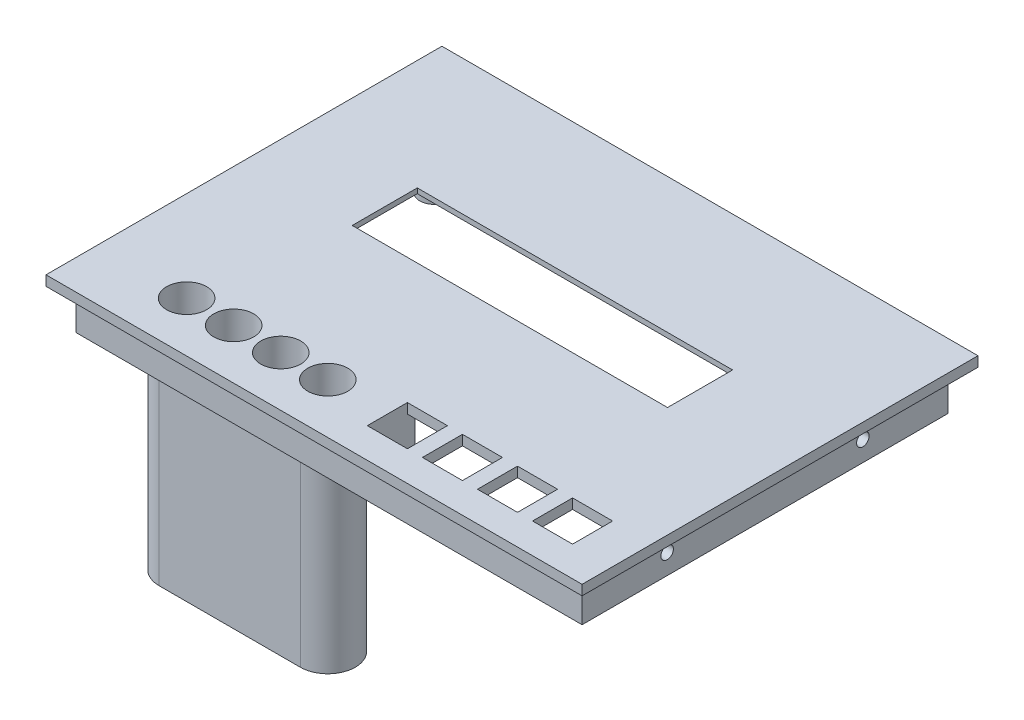
from build123d import *
from build123d.topology import SkipClean

# Parameters (mm, degrees)
SKETCH1_W                 = 78.1
SKETCH1_H                 = 55.9
BOSS_EXTRUDE1_DEPTH       = 3
SKETCH2_R                 = 1.25
CUT_EXTRUDE1_DEPTH        = 68
SKETCH4_W                 = 82.1
SKETCH4_H                 = 59.9
SKETCH4_W_2               = 78.1
SKETCH4_H_2               = 55.9
BOSS_EXTRUDE3_DEPTH       = 3
SKETCH6_R                 = 3
SKETCH6_R_2               = 1.25
BOSS_EXTRUDE4_DEPTH       = 3.5
SKETCH7_W                 = 82.1
SKETCH7_H                 = 16.2
BOSS_EXTRUDE5_DEPTH       = 3
SKETCH8_W                 = 82.1
SKETCH8_H                 = 50.5
BOSS_EXTRUDE6_DEPTH       = 3
SKETCH10_W                = 76.1
SKETCH10_H                = 3
BOSS_EXTRUDE7_DEPTH       = 20
SKETCH12_W                = 79.1
SKETCH12_H                = 50.5
BOSS_EXTRUDE8_DEPTH       = 3
SKETCH17_W                = 105.1
SKETCH17_H                = 50.5
BOSS_EXTRUDE13_DEPTH      = 1
BOSS_EXTRUDE13_DEPTH_BACK = 2
SKETCH18_W                = 11.5
SKETCH18_H                = 7.7
SKETCH18_W_2              = 39.6
SKETCH18_H_2              = 9
CUT_EXTRUDE4_DEPTH        = 9
SKETCH19_W                = 80.1
SKETCH19_H                = 50.5
BOSS_EXTRUDE14_DEPTH      = 3
SKETCH20_R                = 19
SKETCH20_R_2              = 1.5
CUT_EXTRUDE5_DEPTH        = 3
SKETCH22_R                = 2.5
CUT_EXTRUDE6_DEPTH        = 3
SKETCH23_R                = 1.5
BOSS_EXTRUDE16_DEPTH      = 3
SKETCH25_W                = 108.1
SKETCH25_H                = 50.5
CUT_EXTRUDE8_DEPTH        = 0.5
SKETCH26_W                = 79.6
SKETCH26_H                = 50.5
CUT_EXTRUDE9_DEPTH        = 0.5
SKETCH27_W                = 107.6
SKETCH27_H                = 50.5
CUT_EXTRUDE10_DEPTH       = 0.5
SKETCH28_W                = 79.1
SKETCH28_H                = 50.5
CUT_EXTRUDE11_DEPTH       = 0.5
SKETCH30_W                = 101.1
SKETCH30_H                = 73.1
BOSS_EXTRUDE17_DEPTH      = 2
BOSS_EXTRUDE17_DEPTH_BACK = 6
SKETCH31_W                = 39.6
SKETCH31_H                = 15.2
CUT_EXTRUDE12_DEPTH       = 18
SKETCH32_R                = 4
CUT_EXTRUDE13_DEPTH       = 788
SKETCH35_W                = 128.237297138
SKETCH35_H                = 101.417338931
CUT_EXTRUDE16_DEPTH       = 109
SKETCH36_W                = 107.1
SKETCH36_H                = 79.1
SKETCH36_W_2              = 102.1
SKETCH36_H_2              = 74.1
BOSS_EXTRUDE18_DEPTH      = 2
SKETCH37_W                = 107.1
SKETCH37_H                = 79.1
SKETCH37_W_2              = 102.1
SKETCH37_H_2              = 74.1
CUT_EXTRUDE17_DEPTH       = 6
SKETCH38_W                = 102.1
SKETCH38_H                = 74.1
SKETCH38_W_2              = 42.302719986
SKETCH38_H_2              = 18.764227688
BOSS_EXTRUDE19_DEPTH      = 2
SKETCH39_W                = 98.1
SKETCH39_H                = 70.1
CUT_EXTRUDE18_DEPTH       = 6
SKETCH40_R                = 4
BOSS_EXTRUDE21_DEPTH      = 20
SKETCH43_W                = 43.5
SKETCH43_H                = 1.5
CUT_EXTRUDE19_DEPTH       = 20
SKETCH44_W                = 22
SKETCH44_H                = 1.5
CUT_EXTRUDE20_DEPTH       = 20
FILLET1_R                 = 3
SKETCH45_W                = 73.258832398
SKETCH45_H                = 44.668177242
CUT_EXTRUDE21_DEPTH       = 63
CUT_EXTRUDE22_DEPTH       = 380
CUT_EXTRUDE22_DEPTH_BACK  = 374
BOSS_EXTRUDE23_DEPTH      = 2
SKETCH50_R                = 4
BOSS_EXTRUDE24_DEPTH      = 23
FILLET2_R                 = 3
SKETCH51_W                = 22
SKETCH51_H                = 0.5
CUT_EXTRUDE23_DEPTH       = 23
SKETCH52_W                = 22
SKETCH52_H                = 0.5
CUT_EXTRUDE24_DEPTH       = 23
SKETCH53_W                = 8
SKETCH53_H                = 8
CUT_EXTRUDE25_DEPTH       = 23
CUT_EXTRUDE26_DEPTH       = 23
SKETCH56_W                = 3.4
SKETCH56_H                = 1.5
SKETCH56_H_2              = 8
BOSS_EXTRUDE25_DEPTH      = 6
SKETCH58_W                = 4.9
SKETCH58_H                = 11
BOSS_EXTRUDE26_DEPTH      = 6
SKETCH61_R                = 1
CUT_EXTRUDE27_DEPTH       = 6
SKETCH62_W                = 3.4
SKETCH62_H                = 15.6
BOSS_EXTRUDE27_DEPTH      = 6
SKETCH64_W                = 4.9
SKETCH64_H                = 11
SKETCH64_R                = 1
SKETCH64_W_2              = 1.5
SKETCH64_H_2              = 70.1
BOSS_EXTRUDE28_DEPTH      = 2
BOSS_EXTRUDE29_DEPTH      = 8
SKETCH67_W                = 107.1
SKETCH67_H                = 79.1
SKETCH67_R                = 4
SKETCH67_W_2              = 8
SKETCH67_H_2              = 8
BOSS_EXTRUDE30_DEPTH      = 22
SKETCH68_W                = 8.1
SKETCH68_H                = 59.1
CUT_EXTRUDE28_DEPTH       = 22
SKETCH70_R                = 1.25
CUT_EXTRUDE29_DEPTH       = 22
SKETCH71_W                = 63
SKETCH71_H                = 13
CUT_EXTRUDE30_DEPTH       = 22
SKETCH72_W                = 72.2
SKETCH72_H                = 25
CUT_EXTRUDE31_DEPTH       = 1
SKETCH73_R                = 2.930769111
SKETCH73_R_2              = 1.25
SKETCH73_R_3              = 2.93
SKETCH73_W                = 75
SKETCH73_H                = 27.649527195
SKETCH73_W_2              = 72.2
SKETCH73_H_2              = 25
BOSS_EXTRUDE31_DEPTH      = 3
SKETCH74_R                = 2.93
SKETCH74_R_2              = 1.25
SKETCH74_R_3              = 2.930769111
BOSS_EXTRUDE32_DEPTH      = 3.5
SKETCH75_W                = 41
SKETCH75_H                = 1.5
BOSS_EXTRUDE33_DEPTH      = 22
SKETCH76_R                = 1.25
BOSS_EXTRUDE34_DEPTH      = 2
SKETCH78_W                = 107.1
SKETCH78_H                = 79.1
SKETCH78_W_2              = 101.1
SKETCH78_H_2              = 73.1
CUT_EXTRUDE32_DEPTH       = 22
SKETCH79_W                = 20.5
SKETCH79_H                = 1.5
CUT_EXTRUDE33_DEPTH       = 22
SKETCH80_W                = 77.6
SKETCH80_H                = 1.5
SKETCH80_R                = 1
SKETCH80_W_2              = 4.9
SKETCH80_H_2              = 26.6
CUT_EXTRUDE34_DEPTH       = 22
SKETCH81_R                = 1
CUT_EXTRUDE35_DEPTH       = 22
SKETCH82_W                = 41
SKETCH82_H                = 11
CUT_EXTRUDE36_DEPTH       = 22
SKETCH85_R                = 1.25
CUT_EXTRUDE38_DEPTH       = 9
SKETCH86_R                = 1.25
CUT_EXTRUDE39_DEPTH       = 9
SKETCH88_W                = 20.5
SKETCH88_H                = 1.5
BOSS_EXTRUDE35_DEPTH      = 4
SKETCH89_W                = 4.9
SKETCH89_H                = 45
BOSS_EXTRUDE36_DEPTH      = 9
SKETCH90_W                = 4.9
SKETCH90_H                = 73.1
BOSS_EXTRUDE37_DEPTH      = 9
SKETCH91_R                = 1.25
CUT_EXTRUDE41_DEPTH       = 9
SKETCH92_W                = 61.396361311
SKETCH92_H                = 8
BOSS_EXTRUDE38_DEPTH      = 4.9
SKETCH94_R                = 1.25
CUT_EXTRUDE42_DEPTH       = 4.9
SKETCH96_R                = 1.25
CUT_EXTRUDE43_DEPTH       = 9.9
SKETCH97_R                = 1.25
CUT_EXTRUDE44_DEPTH       = 9.9


with BuildPart() as part:
    # Sketch1 → Boss-Extrude1 (new body)
    with BuildSketch(Plane(origin=(0, 0, 0), x_dir=(1, 0, 0), z_dir=(0, 1, 0))):
        Rectangle(SKETCH1_W, SKETCH1_H)
    extrude(amount=BOSS_EXTRUDE1_DEPTH)

    # Sketch2 → Cut-Extrude1 (cut)
    with BuildSketch(Plane(origin=(0, 3, 0), x_dir=(1, 0, 0), z_dir=(0, 1, 0))):
        with Locations(Location((-35.9, 20.9, 0), (0, 0, 270))):
            Circle(SKETCH2_R)
        with Locations(Location((-35.9, -24.8, 0), (0, 0, 270))):
            Circle(SKETCH2_R)
        with Locations(Location((35.9, -24.8, 0), (0, 0, 270))):
            Circle(SKETCH2_R)
        with Locations(Location((35.9, 24.8, 0), (0, 0, 270))):
            Circle(SKETCH2_R)
    extrude(amount=-CUT_EXTRUDE1_DEPTH, mode=Mode.SUBTRACT)

    # Sketch4 → Boss-Extrude3 (add)
    with BuildSketch(Plane(origin=(0, 0, 0), x_dir=(-1, 0, 0), z_dir=(0, -1, 0))):
        Rectangle(SKETCH4_W, SKETCH4_H)
        Rectangle(SKETCH4_W_2, SKETCH4_H_2, mode=Mode.SUBTRACT)
    extrude(amount=-BOSS_EXTRUDE3_DEPTH)

    # Sketch6 → Boss-Extrude4 (add)
    with BuildSketch(Plane(origin=(0, 3, 0), x_dir=(1, 0, 0), z_dir=(0, 1, 0))):
        with Locations(Location((-35.9, 20.9, 0), (0, 0, 90))):
            Circle(SKETCH6_R)
        with Locations(Location((-35.9, 20.9, 0), (0, 0, 270))):
            Circle(SKETCH6_R_2, mode=Mode.SUBTRACT)
        with Locations(Location((35.9, 24.8, 0), (0, 0, 90))):
            Circle(SKETCH6_R)
        with Locations(Location((35.9, 24.8, 0), (0, 0, 270))):
            Circle(SKETCH6_R_2, mode=Mode.SUBTRACT)
        with Locations(Location((35.9, -24.8, 0), (0, 0, 90))):
            Circle(SKETCH6_R)
        with Locations(Location((35.9, -24.8, 0), (0, 0, 270))):
            Circle(SKETCH6_R_2, mode=Mode.SUBTRACT)
        with Locations(Location((-35.9, -24.8, 0), (0, 0, 90))):
            Circle(SKETCH6_R)
        with Locations(Location((-35.9, -24.8, 0), (0, 0, 270))):
            Circle(SKETCH6_R_2, mode=Mode.SUBTRACT)
    extrude(amount=BOSS_EXTRUDE4_DEPTH)

    # Sketch7 → Boss-Extrude5 (add)
    with BuildSketch(Plane(origin=(0, 0, 0), x_dir=(-1, 0, 0), z_dir=(0, -1, 0))):
        with Locations((0, 38.05)):
            Rectangle(SKETCH7_W, SKETCH7_H)
    extrude(amount=-BOSS_EXTRUDE5_DEPTH)

    # Sketch8 → Boss-Extrude6 (add)
    with BuildSketch(Plane(origin=(0, 0, -46.15), x_dir=(-1, 0, 0), z_dir=(0, 0, -1))):
        with Locations((0, 25.25)):
            Rectangle(SKETCH8_W, SKETCH8_H)
    extrude(amount=BOSS_EXTRUDE6_DEPTH)

    # Sketch10 → Boss-Extrude7 (add)
    with BuildSketch(Plane(origin=(41.05, 0, 0), x_dir=(0, 0, -1), z_dir=(1, 0, 0))):
        Polygon((49.15, 50.5), (46.15, 50.5), (46.15, 3), (46.15, 0), (49.15, 0), align=None)
        with Locations((8.1, 1.5)):
            Rectangle(SKETCH10_W, SKETCH10_H)
    extrude(amount=BOSS_EXTRUDE7_DEPTH)

    # Sketch12 → Boss-Extrude8 (add)
    with BuildSketch(Plane.ZY.offset(41.05)):
        with Locations((-9.6, 25.25)):
            Rectangle(SKETCH12_W, SKETCH12_H)
    extrude(amount=BOSS_EXTRUDE8_DEPTH)

    # Sketch17 → Boss-Extrude13 (add, two sides)
    with BuildSketch(Plane.XY.offset(29.95)) as boss_extrude13_sk:
        with Locations((8.5, 25.25)):
            Rectangle(SKETCH17_W, SKETCH17_H)
    extrude(amount=BOSS_EXTRUDE13_DEPTH)
    extrude(boss_extrude13_sk.sketch, amount=-BOSS_EXTRUDE13_DEPTH_BACK)

    # Sketch18 → Cut-Extrude4 (cut)
    with BuildSketch(Plane(origin=(0, 0, 27.95), x_dir=(-1, 0, 0), z_dir=(0, 0, -1))):
        with Locations((-21.6, 9.95)):
            Rectangle(SKETCH18_W, SKETCH18_H)
        with Locations((11.35, 17.6)):
            Rectangle(SKETCH18_W_2, SKETCH18_H_2)
    extrude(amount=-CUT_EXTRUDE4_DEPTH, mode=Mode.SUBTRACT)

    # Sketch19 → Boss-Extrude14 (add)
    with BuildSketch(Plane(origin=(61.05, 0, 0), x_dir=(0, 0, -1), z_dir=(1, 0, 0))):
        with Locations((9.1, 25.25)):
            Rectangle(SKETCH19_W, SKETCH19_H)
    extrude(amount=BOSS_EXTRUDE14_DEPTH)

    # Sketch20 → Cut-Extrude5 (cut)
    with BuildSketch(Plane.ZY.offset(-61.05)):
        with Locations((-24.15, 25)):
            Circle(SKETCH20_R)
        with Locations((-8.4, 40.75)):
            Circle(SKETCH20_R_2)
        with Locations((-39.9, 40.75)):
            Circle(SKETCH20_R_2)
        with Locations((-8.4, 9.25)):
            Circle(SKETCH20_R_2)
        with Locations((-39.9, 9.25)):
            Circle(SKETCH20_R_2)
    extrude(amount=-CUT_EXTRUDE5_DEPTH, mode=Mode.SUBTRACT)

    # Sketch22 → Cut-Extrude6 (cut)
    with BuildSketch(Plane(origin=(-41.05, 0, 0), x_dir=(0, 0, -1), z_dir=(1, 0, 0))):
        with Locations((14.225, 12.6875)):
            Circle(SKETCH22_R)
        with Locations((14.225, 22.0625)):
            Circle(SKETCH22_R)
        with Locations((18.5, 17.375)):
            Circle(SKETCH22_R)
        with Locations((22.775, 22.0625)):
            Circle(SKETCH22_R)
        with Locations((22.775, 12.6875)):
            Circle(SKETCH22_R)
        with Locations((14.225, 31.4375)):
            Circle(SKETCH22_R)
        with Locations((18.5, 26.75)):
            Circle(SKETCH22_R)
        with Locations((22.775, 31.4375)):
            Circle(SKETCH22_R)
        with Locations((18.5, 36.125)):
            Circle(SKETCH22_R)
        with Locations((14.225, 40.8125)):
            Circle(SKETCH22_R)
        with Locations((22.775, 40.8125)):
            Circle(SKETCH22_R)
        with Locations((27.05, 36.125)):
            Circle(SKETCH22_R)
        with Locations((31.325, 40.8125)):
            Circle(SKETCH22_R)
        with Locations((39.875, 40.8125)):
            Circle(SKETCH22_R)
        with Locations((35.6, 36.125)):
            Circle(SKETCH22_R)
        with Locations((39.875, 31.4375)):
            Circle(SKETCH22_R)
        with Locations((31.325, 31.4375)):
            Circle(SKETCH22_R)
        with Locations((27.05, 26.75)):
            Circle(SKETCH22_R)
        with Locations((31.325, 22.0625)):
            Circle(SKETCH22_R)
        with Locations((39.875, 22.0625)):
            Circle(SKETCH22_R)
        with Locations((35.6, 26.75)):
            Circle(SKETCH22_R)
        with Locations((27.05, 17.375)):
            Circle(SKETCH22_R)
        with Locations((31.325, 12.6875)):
            Circle(SKETCH22_R)
        with Locations((39.875, 12.6875)):
            Circle(SKETCH22_R)
        with Locations((35.6, 17.375)):
            Circle(SKETCH22_R)
        with Locations((18.5, 8)):
            Circle(SKETCH22_R)
        with Locations((27.05, 8)):
            Circle(SKETCH22_R)
        with Locations((35.6, 8)):
            Circle(SKETCH22_R)
    extrude(amount=-CUT_EXTRUDE6_DEPTH, mode=Mode.SUBTRACT)

    # Sketch23 → Boss-Extrude16 (add)
    with BuildSketch(Plane(origin=(64.05, 0, 0), x_dir=(0, 0, -1), z_dir=(1, 0, 0))):
        with Locations((8.4, 9.25)):
            Circle(SKETCH23_R)
        with Locations((39.9, 40.75)):
            Circle(SKETCH23_R)
    extrude(amount=-BOSS_EXTRUDE16_DEPTH)

    # Sketch25 → Cut-Extrude8 (cut)
    with BuildSketch(Plane.XY.offset(30.95)):
        with Locations((10, 25.25)):
            Rectangle(SKETCH25_W, SKETCH25_H)
    extrude(amount=-CUT_EXTRUDE8_DEPTH, mode=Mode.SUBTRACT)

    # Sketch26 → Cut-Extrude9 (cut)
    with BuildSketch(Plane(origin=(64.05, 0, 0), x_dir=(0, 0, -1), z_dir=(1, 0, 0))):
        with Locations((9.35, 25.25)):
            Rectangle(SKETCH26_W, SKETCH26_H)
    extrude(amount=-CUT_EXTRUDE9_DEPTH, mode=Mode.SUBTRACT)

    # Sketch27 → Cut-Extrude10 (cut)
    with BuildSketch(Plane(origin=(0, 0, -49.15), x_dir=(-1, 0, 0), z_dir=(0, 0, -1))):
        with Locations((-9.75, 25.25)):
            Rectangle(SKETCH27_W, SKETCH27_H)
    extrude(amount=-CUT_EXTRUDE10_DEPTH, mode=Mode.SUBTRACT)

    # Sketch28 → Cut-Extrude11 (cut)
    with BuildSketch(Plane.ZY.offset(44.05)):
        with Locations((-9.1, 25.25)):
            Rectangle(SKETCH28_W, SKETCH28_H)
    extrude(amount=-CUT_EXTRUDE11_DEPTH, mode=Mode.SUBTRACT)

    # Sketch31 → Cut-Extrude12 (cut)
    with BuildSketch(Plane(origin=(0, 3, 0), x_dir=(1, 0, 0), z_dir=(0, 1, 0))):
        with Locations((-11.35, -20.35)):
            Rectangle(SKETCH31_W, SKETCH31_H)
    extrude(amount=-CUT_EXTRUDE12_DEPTH, mode=Mode.SUBTRACT)


with BuildPart() as body_2:
    # Sketch30 → Boss-Extrude17 (new, two sides)
    with BuildSketch(Plane(origin=(0, 50.5, 0), x_dir=(1, 0, 0), z_dir=(0, 1, 0))) as boss_extrude17_sk:
        with Locations((10, 9.1)):
            Rectangle(SKETCH30_W, SKETCH30_H)
    extrude(amount=BOSS_EXTRUDE17_DEPTH)
    extrude(boss_extrude17_sk.sketch, amount=-BOSS_EXTRUDE17_DEPTH_BACK)


with BuildPart() as cut_extrude13_tool:
    # Sketch32 → Cut-Extrude13 (new body)
    with BuildSketch(Plane.XZ):
        with Locations(Location((2.73, 16.581093047, 0), (0, 0, 270))):
            Circle(SKETCH32_R)
        with Locations(Location((-6.607184449, 16.581093047, 0), (0, 0, 270))):
            Circle(SKETCH32_R)
        with Locations(Location((-16.03, 16.55, 0), (0, 0, 270))):
            Circle(SKETCH32_R)
        with Locations(Location((-25.43, 16.55, 0), (0, 0, 270))):
            Circle(SKETCH32_R)
    extrude(amount=-CUT_EXTRUDE13_DEPTH)


with BuildPart() as part_1:
    add(part.part)

    # Cut-Extrude13: cut by cut_extrude13_tool
    add(cut_extrude13_tool.part, mode=Mode.SUBTRACT)

    # Sketch35 → Cut-Extrude16 (cut)
    with BuildSketch(Plane.XY.offset(30.45)):
        with Locations((20.568648569, -6.208669466)):
            Rectangle(SKETCH35_W, SKETCH35_H)
    extrude(amount=-CUT_EXTRUDE16_DEPTH, mode=Mode.SUBTRACT)

    # Sketch36 → Boss-Extrude18 (add)
    with BuildSketch(Plane(origin=(0, 50.5, 0), x_dir=(1, 0, 0), z_dir=(0, 1, 0))):
        with Locations((10, 9.1)):
            Rectangle(SKETCH36_W, SKETCH36_H)
        with Locations((10, 9.1)):
            Rectangle(SKETCH36_W_2, SKETCH36_H_2, mode=Mode.SUBTRACT)
    extrude(amount=BOSS_EXTRUDE18_DEPTH)

    # Sketch37 → Cut-Extrude17 (cut)
    with BuildSketch(Plane(origin=(0, 44.5, 0), x_dir=(-1, 0, 0), z_dir=(0, -1, 0))):
        with Locations((-10, 9.1)):
            Rectangle(SKETCH37_W, SKETCH37_H)
        with Locations((-10, 9.1)):
            Rectangle(SKETCH37_W_2, SKETCH37_H_2, mode=Mode.SUBTRACT)
    extrude(amount=-CUT_EXTRUDE17_DEPTH, mode=Mode.SUBTRACT)



with BuildPart() as body_2_1:
    add(body_2.part)

    # Cut-Extrude13: cut by cut_extrude13_tool
    add(cut_extrude13_tool.part, mode=Mode.SUBTRACT)


with BuildPart() as part_2:
    add(part_1.part)

    add(body_2_1.part)  # Boss-Extrude19 merges body 2
    # Sketch38 → Boss-Extrude19 (add)
    with BuildSketch(Plane(origin=(0, 52.5, 0), x_dir=(1, 0, 0), z_dir=(0, 1, 0))):
        with Locations((10, 9.1)):
            Rectangle(SKETCH38_W, SKETCH38_H)
        with Locations((-11.151359993, -15.547609528)):
            Rectangle(SKETCH38_W_2, SKETCH38_H_2, mode=Mode.SUBTRACT)
    extrude(amount=-BOSS_EXTRUDE19_DEPTH)

    # Sketch39 → Cut-Extrude18 (cut)
    with BuildSketch(Plane(origin=(0, 44.5, 0), x_dir=(-1, 0, 0), z_dir=(0, -1, 0))):
        with Locations((-10, 9.1)):
            Rectangle(SKETCH39_W, SKETCH39_H)
    extrude(amount=-CUT_EXTRUDE18_DEPTH, mode=Mode.SUBTRACT)

    # Sketch40 → Boss-Extrude21 (add)
    with BuildSketch(Plane(origin=(0, 50.5, 0), x_dir=(-1, 0, 0), z_dir=(0, -1, 0))):
        with BuildLine():
            Line((25.43, -11.181722504), (-2.73, -11.243908599))
            ThreePointArc((-2.73, -11.243908599), (-8.067184449, -16.581093047), (-2.73, -21.918277496))
            Line((-2.73, -21.918277496), (25.43, -21.918277496))
            ThreePointArc((25.43, -21.918277496), (30.798277496, -16.55), (25.43, -11.181722504))
        make_face()
        with Locations(Location((6.607184449, -16.581093047, 0), (0, 0, 90))):
            Circle(SKETCH40_R, mode=Mode.SUBTRACT)
        with Locations(Location((16.03, -16.55, 0), (0, 0, 90))):
            Circle(SKETCH40_R, mode=Mode.SUBTRACT)
        with Locations(Location((25.43, -16.55, 0), (0, 0, 90))):
            Circle(SKETCH40_R, mode=Mode.SUBTRACT)
        with Locations(Location((-2.73, -16.581093047, 0), (0, 0, 90))):
            Circle(SKETCH40_R, mode=Mode.SUBTRACT)
    extrude(amount=BOSS_EXTRUDE21_DEPTH)

    # Sketch43 → Cut-Extrude19 (cut)
    with BuildSketch(Plane.ZY.offset(-59.05)):
        with Locations((-22.4, 45.25)):
            Rectangle(SKETCH43_W, SKETCH43_H)
    extrude(amount=-CUT_EXTRUDE19_DEPTH, mode=Mode.SUBTRACT)

    # Sketch44 → Cut-Extrude20 (cut)
    with BuildSketch(Plane.XY.offset(-44.15)):
        with Locations((49.55, 45.25)):
            Rectangle(SKETCH44_W, SKETCH44_H)
    extrude(amount=-CUT_EXTRUDE20_DEPTH, mode=Mode.SUBTRACT)

    # Fillet1
    fillet1_edges = [part_2.edges().sort_by_distance(p)[0] for p in [
        (-11.35, 50.5, 21.918277496),
        (-30.798277496, 50.5, 16.55),
        (-11.35, 50.5, 11.212815551),
        (8.067184449, 50.5, 16.581093047),
    ]]
    fillet(fillet1_edges, radius=FILLET1_R)

    # Sketch45 → Cut-Extrude21 (cut)
    with BuildSketch(Plane(origin=(0, 50.5, 0), x_dir=(-1, 0, 0), z_dir=(0, -1, 0))):
        with Locations((2.420583801, -3.615911379)):
            Rectangle(SKETCH45_W, SKETCH45_H)
    extrude(amount=CUT_EXTRUDE21_DEPTH, mode=Mode.SUBTRACT)

    # Sketch3 → Cut-Extrude22 (cut, two sides)
    with BuildSketch(Plane(origin=(0, 3, 0), x_dir=(1, 0, 0), z_dir=(0, 1, 0))) as cut_extrude22_sk:
        with BuildLine():
            ThreePointArc((-21.45, -20.45), (-25.45, -16.45), (-29.45, -20.45))
            Line((-29.45, -20.45), (-25.45, -20.45))
            Line((-25.45, -20.45), (-21.45, -20.45))
        make_face()
        with BuildLine():
            ThreePointArc((-29.45, -20.45), (-28.278427125, -23.278427125), (-25.45, -24.45))
            Line((-25.45, -24.45), (-25.45, -20.45))
            Line((-25.45, -20.45), (-29.45, -20.45))
        make_face()
        with BuildLine():
            Line((-25.45, -20.45), (-25.45, -24.45))
            ThreePointArc((-25.45, -24.45), (-22.621572875, -23.278427125), (-21.45, -20.45))
            Line((-21.45, -20.45), (-25.45, -20.45))
        make_face()
        with BuildLine():
            ThreePointArc((-20.05, -20.45), (-18.878427125, -23.278427125), (-16.05, -24.45))
            Line((-16.05, -24.45), (-16.05, -20.45))
            Line((-16.05, -20.45), (-20.05, -20.45))
        make_face()
        with BuildLine():
            Line((-16.05, -20.45), (-16.05, -24.45))
            ThreePointArc((-16.05, -24.45), (-13.221572875, -23.278427125), (-12.05, -20.45))
            ThreePointArc((-12.05, -20.45), (-16.05, -16.45), (-20.05, -20.45))
            Line((-20.05, -20.45), (-16.05, -20.45))
        make_face()
        with BuildLine():
            ThreePointArc((-2.65, -20.45), (-9.478427125, -17.621572875), (-6.65, -24.45))
            Line((-6.65, -24.45), (-6.65, -20.45))
            Line((-6.65, -20.45), (-2.65, -20.45))
        make_face()
        with BuildLine():
            Line((-6.65, -20.45), (-6.65, -24.45))
            ThreePointArc((-6.65, -24.45), (-3.821572875, -23.278427125), (-2.65, -20.45))
            Line((-2.65, -20.45), (-6.65, -20.45))
        make_face()
        with BuildLine():
            ThreePointArc((-1.25, -20.45), (-0.078427125, -23.278427125), (2.75, -24.45))
            Line((2.75, -24.45), (2.75, -20.45))
            Line((2.75, -20.45), (-1.25, -20.45))
        make_face()
        with BuildLine():
            Line((2.75, -20.45), (2.75, -24.45))
            ThreePointArc((2.75, -24.45), (5.578427125, -23.278427125), (6.75, -20.45))
            Line((6.75, -20.45), (2.75, -20.45))
        make_face()
        with BuildLine():
            Line((2.75, -20.45), (6.75, -20.45))
            ThreePointArc((6.75, -20.45), (2.75, -16.45), (-1.25, -20.45))
            Line((-1.25, -20.45), (2.75, -20.45))
        make_face()
    extrude(amount=CUT_EXTRUDE22_DEPTH, mode=Mode.SUBTRACT)
    extrude(cut_extrude22_sk.sketch, amount=-CUT_EXTRUDE22_DEPTH_BACK, mode=Mode.SUBTRACT)

    # Sketch49 → Boss-Extrude23 (add)
    with BuildSketch(Plane(origin=(0, 50.5, 0), x_dir=(-1, 0, 0), z_dir=(0, -1, 0))):
        with BuildLine():
            ThreePointArc((-6.241065865, -18.497448048), (-2.729322601, -16.450053445), (0.761065865, -18.533644999))
            ThreePointArc((0.761065865, -18.533644999), (1.140675875, -17.589987625), (1.27, -16.581093047))
            ThreePointArc((1.27, -16.581093047), (-3.718872221, -12.70525356), (-6.241065865, -18.497448048))
        make_face()
        with BuildLine():
            ThreePointArc((3.127745115, -18.554288913), (6.605736408, -16.450244916), (10.129439334, -18.476804135))
            ThreePointArc((10.129439334, -18.476804135), (10.485909725, -17.558584853), (10.607184449, -16.581093047))
            ThreePointArc((10.607184449, -16.581093047), (5.586830916, -12.713422086), (3.127745115, -18.554288913))
        make_face()
        with BuildLine():
            ThreePointArc((12.547568292, -18.517909906), (16.029487449, -16.450052596), (19.532431708, -18.482090094))
            ThreePointArc((19.532431708, -18.482090094), (19.90361116, -17.547565328), (20.03, -16.55))
            ThreePointArc((20.03, -16.55), (15.012583377, -12.681555427), (12.547568292, -18.517909906))
        make_face()
        with BuildLine():
            ThreePointArc((21.947568292, -18.517909906), (25.429487449, -16.450052596), (28.932431708, -18.482090094))
            ThreePointArc((28.932431708, -18.482090094), (29.30361116, -17.547565328), (29.43, -16.55))
            ThreePointArc((29.43, -16.55), (24.412583377, -12.681555427), (21.947568292, -18.517909906))
        make_face()
    extrude(amount=-BOSS_EXTRUDE23_DEPTH)

    # Sketch50 → Boss-Extrude24 (add)
    with SkipClean():  # the faces are left unmerged after this step: merging them gives an invalid solid
        with BuildSketch(Plane(origin=(0, 50.5, 0), x_dir=(-1, 0, 0), z_dir=(0, -1, 0))):
            with BuildLine():
                Line((-2.75, -25.95), (25.45, -25.95))
                ThreePointArc((25.45, -25.95), (30.95, -20.45), (25.45, -14.95))
                Line((25.45, -14.95), (-2.75, -14.95))
                ThreePointArc((-2.75, -14.95), (-8.25, -20.45), (-2.75, -25.95))
            make_face()
            with Locations(Location((16.05, -20.45, 0), (0, 0, 90))):
                Circle(SKETCH50_R, mode=Mode.SUBTRACT)
            with Locations(Location((6.65, -20.45, 0), (0, 0, 90))):
                Circle(SKETCH50_R, mode=Mode.SUBTRACT)
            with Locations(Location((25.45, -20.45, 0), (0, 0, 90))):
                Circle(SKETCH50_R, mode=Mode.SUBTRACT)
            with Locations(Location((-2.75, -20.45, 0), (0, 0, 90))):
                Circle(SKETCH50_R, mode=Mode.SUBTRACT)
        extrude(amount=BOSS_EXTRUDE24_DEPTH)

    # Fillet2
    fillet2_edges = [part_2.edges().sort_by_distance(p)[0] for p in [
        (-11.35, 50.5, 14.95),
        (8.25, 50.5, 20.45),
        (-30.95, 50.5, 20.45),
    ]]
    fillet(fillet2_edges, radius=FILLET2_R)

    # Sketch51 → Cut-Extrude23 (cut)
    with SkipClean():  # the faces are left unmerged after this step: merging them gives an invalid solid
        with BuildSketch(Plane(origin=(0, 0, -45.65), x_dir=(-1, 0, 0), z_dir=(0, 0, -1))):
            with Locations((-49.55, 46.25)):
                Rectangle(SKETCH51_W, SKETCH51_H)
        extrude(amount=-CUT_EXTRUDE23_DEPTH, mode=Mode.SUBTRACT)

    # Sketch52 → Cut-Extrude24 (cut)
    with SkipClean():  # the faces are left unmerged after this step: merging them gives an invalid solid
        with BuildSketch(Plane(origin=(60.55, 0, 0), x_dir=(0, 0, -1), z_dir=(1, 0, 0))):
            with Locations((11.65, 46.25)):
                Rectangle(SKETCH52_W, SKETCH52_H)
        extrude(amount=-CUT_EXTRUDE24_DEPTH, mode=Mode.SUBTRACT)

    # Sketch53 → Cut-Extrude25 (cut)
    with SkipClean():  # the faces are left unmerged after this step: merging them gives an invalid solid
        with BuildSketch(Plane(origin=(0, 52.5, 0), x_dir=(1, 0, 0), z_dir=(0, 1, 0))):
            with Locations((51.65, -20.45)):
                Rectangle(SKETCH53_W, SKETCH53_H)
            with Locations((40.65, -20.45)):
                Rectangle(SKETCH53_W, SKETCH53_H)
            with Locations((29.65, -20.45)):
                Rectangle(SKETCH53_W, SKETCH53_H)
            with Locations((18.65, -20.45)):
                Rectangle(SKETCH53_W, SKETCH53_H)
        extrude(amount=-CUT_EXTRUDE25_DEPTH, mode=Mode.SUBTRACT)

    # Sketch54 → Cut-Extrude26 (cut)
    with SkipClean():  # the faces are left unmerged after this step: merging them gives an invalid solid
        with BuildSketch(Plane(origin=(0, 27.5, 0), x_dir=(-1, 0, 0), z_dir=(0, -1, 0))):
            Polygon((-14.201290386, -14.95), (-2.75, -14.95), (25.45, -14.95), (35.501290386, -14.95), (35.501290386, -4.067232411), (-14.201290386, -4.067232411), align=None)
            with BuildLine():
                Line((35.501290386, -14.95), (25.45, -14.95))
                ThreePointArc((25.45, -14.95), (29.339087297, -16.560912703), (30.95, -20.45))
                ThreePointArc((30.95, -20.45), (29.339087297, -24.339087297), (25.45, -25.95))
                Line((25.45, -25.95), (35.501290386, -25.95))
                Line((35.501290386, -25.95), (35.501290386, -14.95))
            make_face()
            with BuildLine():
                ThreePointArc((-2.75, -25.95), (-8.25, -20.45), (-2.75, -14.95))
                Line((-2.75, -14.95), (-14.201290386, -14.95))
                Line((-14.201290386, -14.95), (-14.201290386, -25.95))
                Line((-14.201290386, -25.95), (-2.75, -25.95))
            make_face()
        extrude(amount=-CUT_EXTRUDE26_DEPTH, mode=Mode.SUBTRACT)

    # Sketch56 → Boss-Extrude25 (add)
    with SkipClean():  # the faces are left unmerged after this step: merging them gives an invalid solid
        with BuildSketch(Plane.XZ.offset(-50.5)):
            with Locations((57.35, 25.2)):
                Rectangle(SKETCH56_W, SKETCH56_H)
            with Locations((57.35, 20.45)):
                Rectangle(SKETCH56_W, SKETCH56_H_2)
            with Locations((57.35, 15.7)):
                Rectangle(SKETCH56_W, SKETCH56_H)
        extrude(amount=BOSS_EXTRUDE25_DEPTH)

    # Sketch58 → Boss-Extrude26 (add)
    with SkipClean():  # the faces are left unmerged after this step: merging them gives an invalid solid
        with BuildSketch(Plane.XZ.offset(-50.5)):
            with Locations((12.2, 20.45)):
                Rectangle(SKETCH58_W, SKETCH58_H)
        extrude(amount=BOSS_EXTRUDE26_DEPTH)

    # Sketch61 → Cut-Extrude27 (cut)
    with SkipClean():  # the faces are left unmerged after this step: merging them gives an invalid solid
        with BuildSketch(Plane(origin=(0, 44.5, 0), x_dir=(-1, 0, 0), z_dir=(0, -1, 0))):
            with Locations(Location((-58.15, -20.45, 0), (0, 0, 90))):
                Circle(SKETCH61_R)
            with Locations(Location((-12.15, -20.45, 0), (0, 0, 90))):
                Circle(SKETCH61_R)
        extrude(amount=-CUT_EXTRUDE27_DEPTH, mode=Mode.SUBTRACT)

    # Sketch62 → Boss-Extrude27 (add)
    with SkipClean():  # the faces are left unmerged after this step: merging them gives an invalid solid
        with BuildSketch(Plane(origin=(0, 44.5, 0), x_dir=(-1, 0, 0), z_dir=(0, -1, 0))):
            with Locations((-57.35, -7.15)):
                Rectangle(SKETCH62_W, SKETCH62_H)
        extrude(amount=-BOSS_EXTRUDE27_DEPTH)

    # Sketch64 → Boss-Extrude28 (add)
    with BuildSketch(Plane.XZ.offset(-44.5)):
        with Locations((12.2, 20.45)):
            Rectangle(SKETCH64_W, SKETCH64_H)
        with Locations(Location((12.15, 20.45, 0), (0, 0, 270))):
            Circle(SKETCH64_R, mode=Mode.SUBTRACT)
        Polygon((55.65, 27.45), (55.65, 25.95), (55.65, -0.65), (60.55, -0.65), (60.55, 27.45), align=None)
        with Locations(Location((58.15, 20.45, 0), (0, 0, 270))):
            Circle(SKETCH64_R, mode=Mode.SUBTRACT)
        Polygon((2.75, 25.95), (9.75, 25.95), (14.65, 25.95), (55.65, 25.95), (55.65, 27.45), (-40.55, 27.45), (-40.55, 25.95), (-39.05, 25.95), (-25.45, 25.95), align=None)
        with Locations((-39.8, -9.1)):
            Rectangle(SKETCH64_W_2, SKETCH64_H_2)
        Polygon((38.55, -44.15), (-39.05, -44.15), (-40.55, -44.15), (-40.55, -45.65), (38.55, -45.65), align=None)
    extrude(amount=BOSS_EXTRUDE28_DEPTH)

    # Sketch65 → Boss-Extrude29 (add)
    with BuildSketch(Plane(origin=(0, 50.5, 0), x_dir=(-1, 0, 0), z_dir=(0, -1, 0))):
        with BuildLine():
            Line((-2.75, -14.95), (-9.75, -14.95))
            Line((-9.75, -14.95), (-9.75, -25.95))
            Line((-9.75, -25.95), (-2.75, -25.95))
            ThreePointArc((-2.75, -25.95), (-8.25, -20.45), (-2.75, -14.95))
        make_face()
    extrude(amount=BOSS_EXTRUDE29_DEPTH)

    # Sketch67 → Boss-Extrude30 (add)
    with BuildSketch(Plane(origin=(0, 52.5, 0), x_dir=(1, 0, 0), z_dir=(0, 1, 0))):
        with Locations((10, 9.1)):
            Rectangle(SKETCH67_W, SKETCH67_H)
        with Locations(Location((2.75, -20.45, 0), (0, 0, 90))):
            Circle(SKETCH67_R, mode=Mode.SUBTRACT)
        with Locations(Location((-6.65, -20.45, 0), (0, 0, 90))):
            Circle(SKETCH67_R, mode=Mode.SUBTRACT)
        with Locations(Location((-16.05, -20.45, 0), (0, 0, 90))):
            Circle(SKETCH67_R, mode=Mode.SUBTRACT)
        with Locations(Location((-25.45, -20.45, 0), (0, 0, 90))):
            Circle(SKETCH67_R, mode=Mode.SUBTRACT)
        with Locations((51.65, -20.45)):
            Rectangle(SKETCH67_W_2, SKETCH67_H_2, mode=Mode.SUBTRACT)
        with Locations((40.65, -20.45)):
            Rectangle(SKETCH67_W_2, SKETCH67_H_2, mode=Mode.SUBTRACT)
        with Locations((29.65, -20.45)):
            Rectangle(SKETCH67_W_2, SKETCH67_H_2, mode=Mode.SUBTRACT)
        with Locations((18.65, -20.45)):
            Rectangle(SKETCH67_W_2, SKETCH67_H_2, mode=Mode.SUBTRACT)
    extrude(amount=BOSS_EXTRUDE30_DEPTH)

    # Sketch68 → Cut-Extrude28 (cut)
    with BuildSketch(Plane.XZ.offset(-50.5)):
        Polygon((14.65, -44.15), (59.05, -44.15), (59.05, -0.65), (55.65, -0.65), (55.65, 16.45), (47.65, 16.45), (44.65, 16.45), (36.65, 16.45), (33.65, 16.45), (25.65, 16.45), (22.65, 16.45), (14.65, 16.45), (14.65, 14.95), align=None)
        Polygon((-30.95, -44.15), (14.65, -44.15), (14.65, 14.95), (-25.45, 14.95), (-30.95, 14.95), align=None)
        with Locations((-35, -14.6)):
            Rectangle(SKETCH68_W, SKETCH68_H)
        Polygon((-39.05, 14.95), (-30.95, 14.95), (-30.95, 20.450000012), (-30.95, 25.95), (-39.05, 25.95), align=None)
        with BuildLine():
            Line((-30.95, 14.95), (-25.45, 14.95))
            ThreePointArc((-25.45, 14.95), (-29.339087301, 16.560912708), (-30.95, 20.450000012))
            Line((-30.95, 20.450000012), (-30.95, 14.95))
        make_face()
        with BuildLine():
            Line((-30.95, 25.95), (-30.95, 20.450000012))
            ThreePointArc((-30.95, 20.450000012), (-29.339087292, 24.339087301), (-25.45, 25.95))
            Line((-25.45, 25.95), (-30.95, 25.95))
        make_face()
    extrude(amount=-CUT_EXTRUDE28_DEPTH, mode=Mode.SUBTRACT)

    # Sketch70 → Cut-Extrude29 (cut)
    with BuildSketch(Plane.XZ.offset(-72.5)):
        with Locations(Location((47.5, -31.1, 0), (0, 0, 270))):
            Circle(SKETCH70_R)
        with Locations(Location((-27.5, -31.1, 0), (0, 0, 270))):
            Circle(SKETCH70_R)
        with Locations(Location((-27.5, -0.1, 0), (0, 0, 270))):
            Circle(SKETCH70_R)
        with Locations(Location((47.5, -0.1, 0), (0, 0, 270))):
            Circle(SKETCH70_R)
    extrude(amount=-CUT_EXTRUDE29_DEPTH, mode=Mode.SUBTRACT)

    # Sketch71 → Cut-Extrude30 (cut)
    with BuildSketch(Plane.XZ.offset(-72.5)):
        with Locations((10, -15.174763597)):
            Rectangle(SKETCH71_W, SKETCH71_H)
    extrude(amount=-CUT_EXTRUDE30_DEPTH, mode=Mode.SUBTRACT)

    # Sketch72 → Cut-Extrude31 (cut)
    with BuildSketch(Plane(origin=(0, 72.5, 0), x_dir=(-1, 0, 0), z_dir=(0, -1, 0))):
        with Locations((-10, 15.174763597)):
            Rectangle(SKETCH72_W, SKETCH72_H)
    extrude(amount=-CUT_EXTRUDE31_DEPTH, mode=Mode.SUBTRACT)

    # Sketch73 → Boss-Extrude31 (add)
    with BuildSketch(Plane(origin=(0, 72.5, 0), x_dir=(-1, 0, 0), z_dir=(0, -1, 0))):
        with Locations((-47.5, 0.1)):
            Circle(SKETCH73_R)
        with Locations(Location((-47.5, 0.1, 0), (0, 0, 90))):
            Circle(SKETCH73_R_2, mode=Mode.SUBTRACT)
        with Locations((27.5, 0.1)):
            Circle(SKETCH73_R)
        with Locations(Location((27.5, 0.1, 0), (0, 0, 90))):
            Circle(SKETCH73_R_2, mode=Mode.SUBTRACT)
        with Locations((27.5, 31.1)):
            Circle(SKETCH73_R_3)
        with Locations(Location((27.5, 31.1, 0), (0, 0, 90))):
            Circle(SKETCH73_R_2, mode=Mode.SUBTRACT)
        with Locations((-47.5, 31.1)):
            Circle(SKETCH73_R_3)
        with Locations(Location((-47.5, 31.1, 0), (0, 0, 90))):
            Circle(SKETCH73_R_2, mode=Mode.SUBTRACT)
        with Locations((-10, 15.174763598)):
            Rectangle(SKETCH73_W, SKETCH73_H)
        with Locations((-10, 15.174763597)):
            Rectangle(SKETCH73_W_2, SKETCH73_H_2, mode=Mode.SUBTRACT)
    extrude(amount=BOSS_EXTRUDE31_DEPTH)

    # Sketch74 → Boss-Extrude32 (add)
    with BuildSketch(Plane(origin=(0, 69.5, 0), x_dir=(-1, 0, 0), z_dir=(0, -1, 0))):
        with Locations(Location((-47.5, 31.1, 0), (0, 0, 270))):
            Circle(SKETCH74_R)
        with Locations(Location((-47.5, 31.1, 0), (0, 0, 90))):
            Circle(SKETCH74_R_2, mode=Mode.SUBTRACT)
        with Locations(Location((-47.5, 0.1, 0), (0, 0, 90))):
            Circle(SKETCH74_R_3)
        with Locations(Location((-47.5, 0.1, 0), (0, 0, 90))):
            Circle(SKETCH74_R_2, mode=Mode.SUBTRACT)
        with Locations(Location((27.5, 0.1, 0), (0, 0, 90))):
            Circle(SKETCH74_R_3)
        with Locations(Location((27.5, 0.1, 0), (0, 0, 90))):
            Circle(SKETCH74_R_2, mode=Mode.SUBTRACT)
        with Locations(Location((27.5, 31.1, 0), (0, 0, 270))):
            Circle(SKETCH74_R)
        with Locations(Location((27.5, 31.1, 0), (0, 0, 90))):
            Circle(SKETCH74_R_2, mode=Mode.SUBTRACT)
    extrude(amount=BOSS_EXTRUDE32_DEPTH)

    # Sketch75 → Boss-Extrude33 (add)
    with BuildSketch(Plane(origin=(0, 72.5, 0), x_dir=(-1, 0, 0), z_dir=(0, -1, 0))):
        with Locations((-35.15, -15.7)):
            Rectangle(SKETCH75_W, SKETCH75_H)
    extrude(amount=BOSS_EXTRUDE33_DEPTH)

    # Sketch76 → Boss-Extrude34 (add)
    with BuildSketch(Plane(origin=(0, 74.5, 0), x_dir=(1, 0, 0), z_dir=(0, 1, 0))):
        with Locations(Location((-27.5, 31.1, 0), (0, 0, 90))):
            Circle(SKETCH76_R)
        with Locations(Location((47.5, 31.1, 0), (0, 0, 90))):
            Circle(SKETCH76_R)
        with Locations(Location((47.5, 0.1, 0), (0, 0, 90))):
            Circle(SKETCH76_R)
        with Locations(Location((-27.5, 0.1, 0), (0, 0, 90))):
            Circle(SKETCH76_R)
    extrude(amount=-BOSS_EXTRUDE34_DEPTH)

    # Sketch78 → Cut-Extrude32 (cut)
    with BuildSketch(Plane(origin=(0, 50.5, 0), x_dir=(-1, 0, 0), z_dir=(0, -1, 0))):
        with Locations((-10, 9.1)):
            Rectangle(SKETCH78_W, SKETCH78_H)
        with Locations((-10, 9.1)):
            Rectangle(SKETCH78_W_2, SKETCH78_H_2, mode=Mode.SUBTRACT)
    extrude(amount=-CUT_EXTRUDE32_DEPTH, mode=Mode.SUBTRACT)

    # Sketch79 → Cut-Extrude33 (cut)
    with BuildSketch(Plane(origin=(0, 46.5, 0), x_dir=(-1, 0, 0), z_dir=(0, -1, 0))):
        Polygon((-59.05, 44.15), (-59.05, 45.65), (-60.55, 45.65), (-60.55, 0.65), (-59.05, 0.65), align=None)
        with Locations((-48.8, 44.9)):
            Rectangle(SKETCH79_W, SKETCH79_H)
    extrude(amount=-CUT_EXTRUDE33_DEPTH, mode=Mode.SUBTRACT)

    # Sketch80 → Cut-Extrude34 (cut)
    with BuildSketch(Plane(origin=(0, 42.5, 0), x_dir=(-1, 0, 0), z_dir=(0, -1, 0))):
        with Locations((0.25, 44.9)):
            Rectangle(SKETCH80_W, SKETCH80_H)
        Polygon((40.55, 45.65), (39.05, 45.65), (39.05, 44.15), (39.05, -25.95), (40.55, -25.95), align=None)
        Polygon((40.55, -25.95), (39.05, -25.95), (25.45, -25.95), (-2.75, -25.95), (-14.65, -25.95), (-55.65, -25.95), (-60.55, -25.95), (-60.55, -27.45), (40.55, -27.45), align=None)
        with BuildLine():
            Line((-14.65, -25.95), (-2.75, -25.95))
            ThreePointArc((-2.75, -25.95), (-8.25, -20.45), (-2.75, -14.95))
            Line((-2.75, -14.95), (-14.65, -14.95))
            Line((-14.65, -14.95), (-14.65, -25.95))
        make_face()
        with Locations(Location((-12.15, -20.45, 0), (0, 0, 90))):
            Circle(SKETCH80_R, mode=Mode.SUBTRACT)
        with Locations((-58.1, -12.65)):
            Rectangle(SKETCH80_W_2, SKETCH80_H_2)
        with Locations(Location((-58.15, -20.45, 0), (0, 0, 90))):
            Circle(SKETCH80_R, mode=Mode.SUBTRACT)
    extrude(amount=-CUT_EXTRUDE34_DEPTH, mode=Mode.SUBTRACT)

    # Sketch81 → Cut-Extrude35 (cut)
    with BuildSketch(Plane(origin=(0, 50.5, 0), x_dir=(-1, 0, 0), z_dir=(0, -1, 0))):
        with Locations(Location((-58.15, -20.45, 0), (0, 0, 90))):
            Circle(SKETCH81_R)
        with Locations(Location((-12.15, -20.45, 0), (0, 0, 90))):
            Circle(SKETCH81_R)
    extrude(amount=-CUT_EXTRUDE35_DEPTH, mode=Mode.SUBTRACT)

    # Sketch82 → Cut-Extrude36 (cut)
    with BuildSketch(Plane(origin=(0, 50.5, 0), x_dir=(-1, 0, 0), z_dir=(0, -1, 0))):
        with Locations((-35.15, -20.45)):
            Rectangle(SKETCH82_W, SKETCH82_H)
    extrude(amount=-CUT_EXTRUDE36_DEPTH, mode=Mode.SUBTRACT)

    # Sketch85 → Cut-Extrude38 (cut)
    with BuildSketch(Plane.ZY.offset(43.55)):
        with Locations((-28.65, 68.5)):
            Circle(SKETCH85_R)
        with Locations((10.45, 68.5)):
            Circle(SKETCH85_R)
    extrude(amount=-CUT_EXTRUDE38_DEPTH, mode=Mode.SUBTRACT)

    # Sketch86 → Cut-Extrude39 (cut)
    with BuildSketch(Plane(origin=(63.55, 0, 0), x_dir=(0, 0, -1), z_dir=(1, 0, 0))):
        with Locations((-10.381828431, 68.627888176)):
            Circle(SKETCH86_R)
    extrude(amount=-CUT_EXTRUDE39_DEPTH, mode=Mode.SUBTRACT)

    # Sketch88 → Boss-Extrude35 (add)
    with BuildSketch(Plane(origin=(0, 68.5, 0), x_dir=(-1, 0, 0), z_dir=(0, -1, 0))):
        with Locations((-48.8, 44.9)):
            Rectangle(SKETCH88_W, SKETCH88_H)
        Polygon((-59.05, 44.15), (-59.05, 45.65), (-60.55, 45.65), (-60.55, 0.65), (-59.05, 0.65), align=None)
    extrude(amount=BOSS_EXTRUDE35_DEPTH)

    # Sketch89 → Boss-Extrude36 (add)
    with BuildSketch(Plane(origin=(0, 64.5, 0), x_dir=(-1, 0, 0), z_dir=(0, -1, 0))):
        with Locations((-58.1, 23.15)):
            Rectangle(SKETCH89_W, SKETCH89_H)
    extrude(amount=-BOSS_EXTRUDE36_DEPTH)

    # Sketch90 → Boss-Extrude37 (add)
    with BuildSketch(Plane(origin=(0, 64.5, 0), x_dir=(-1, 0, 0), z_dir=(0, -1, 0))):
        with Locations((38.1, 9.1)):
            Rectangle(SKETCH90_W, SKETCH90_H)
    extrude(amount=-BOSS_EXTRUDE37_DEPTH)

    # Sketch91 → Cut-Extrude41 (cut)
    with BuildSketch(Plane(origin=(63.55, 0, 0), x_dir=(0, 0, -1), z_dir=(1, 0, 0))):
        with Locations((28.65, 68.5)):
            Circle(SKETCH91_R)
    extrude(amount=-CUT_EXTRUDE41_DEPTH, mode=Mode.SUBTRACT)

    # Sketch92 → Boss-Extrude38 (add)
    with BuildSketch(Plane(origin=(60.55, 0, 0), x_dir=(0, 0, -1), z_dir=(1, 0, 0))):
        with Locations((14.951819345, 68.5)):
            Rectangle(SKETCH92_W, SKETCH92_H)
    extrude(amount=-BOSS_EXTRUDE38_DEPTH)

    # Sketch94 → Cut-Extrude42 (cut)
    with BuildSketch(Plane(origin=(63.55, 0, 0), x_dir=(0, 0, -1), z_dir=(1, 0, 0))):
        with Locations((28.65, 68.5)):
            Circle(SKETCH94_R)
        with Locations((-10.45, 68.5)):
            Circle(SKETCH94_R)
    extrude(amount=-CUT_EXTRUDE42_DEPTH, mode=Mode.SUBTRACT)

    # Sketch96 → Cut-Extrude43 (cut)
    with BuildSketch(Plane.ZY.offset(43.55)):
        with Locations(Location((10.45, 68.5, 0), (0, 0, 180))):
            Circle(SKETCH96_R)
        with Locations(Location((-28.65, 68.5, 0), (0, 0, 180))):
            Circle(SKETCH96_R)
    extrude(amount=-CUT_EXTRUDE43_DEPTH, mode=Mode.SUBTRACT)

    # Sketch97 → Cut-Extrude44 (cut)
    with BuildSketch(Plane(origin=(60.55, 0, 0), x_dir=(0, 0, -1), z_dir=(1, 0, 0))):
        with Locations((28.65, 68.5)):
            Circle(SKETCH97_R)
        with Locations((-10.45, 68.5)):
            Circle(SKETCH97_R)
    extrude(amount=-CUT_EXTRUDE44_DEPTH, mode=Mode.SUBTRACT)


solid = part_2.part
